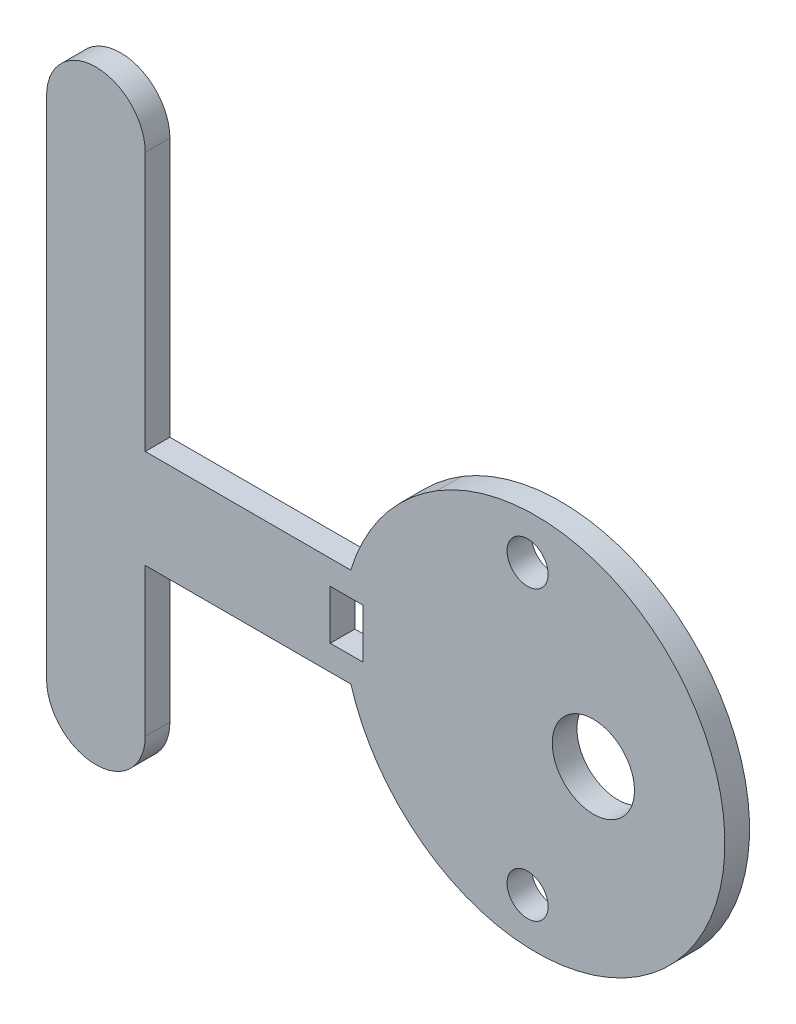
from build123d import *

# Parameters (mm, degrees)
SKETCH_1_R          = 5
SKETCH_1_R_2        = 2.5
EXTRUDE_1_DEPTH     = 3
SKETCH_2_W          = 4
SKETCH_2_H          = 6
CUT_EXTRUDE_1_DEPTH = 3


with BuildPart() as part:
    # 草图1 → 凸台-拉伸1 (new body)
    with BuildSketch(Plane.XY):
        with BuildLine():
            Line((104.204193709, 89.499436202), (104.204193709, 57.999436202))
            Line((104.204193709, 57.999436202), (129.204193709, 57.999436202))
            ThreePointArc((129.204193709, 57.999436202), (133.19157799, 65.772898709), (139.689971603, 71.61214808))
            ThreePointArc((139.689971603, 71.61214808), (174.704134434, 51.947219111), (139.601041877, 32.44147834))
            ThreePointArc((139.601041877, 32.44147834), (133.162334619, 38.267746144), (129.209700495, 45.999436202))
            Line((129.209700495, 45.999436202), (104.204193709, 45.999436202))
            Line((104.204193709, 45.999436202), (104.204193709, 27.999436202))
            ThreePointArc((104.204193709, 27.999436202), (98.204193709, 21.999436202), (92.204193709, 27.999436202))
            Line((92.204193709, 27.999436202), (92.204193709, 89.499436202))
            ThreePointArc((92.204193709, 89.499436202), (98.204193709, 95.499436202), (104.204193709, 89.499436202))
        make_face()
        with Locations((158.704193709, 52.048919583)):
            Circle(SKETCH_1_R, mode=Mode.SUBTRACT)
        with Locations((150.704193709, 69.548919583)):
            Circle(SKETCH_1_R_2, mode=Mode.SUBTRACT)
        with Locations((150.704193709, 34.548919583)):
            Circle(SKETCH_1_R_2, mode=Mode.SUBTRACT)
    extrude(amount=EXTRUDE_1_DEPTH)

    # 草图2 → 切除-拉伸1 (cut)
    with BuildSketch(Plane.XY.offset(3)):
        with Locations((128.704193709, 52.048919583)):
            Rectangle(SKETCH_2_W, SKETCH_2_H)
    extrude(amount=-CUT_EXTRUDE_1_DEPTH, mode=Mode.SUBTRACT)


solid = part.part
